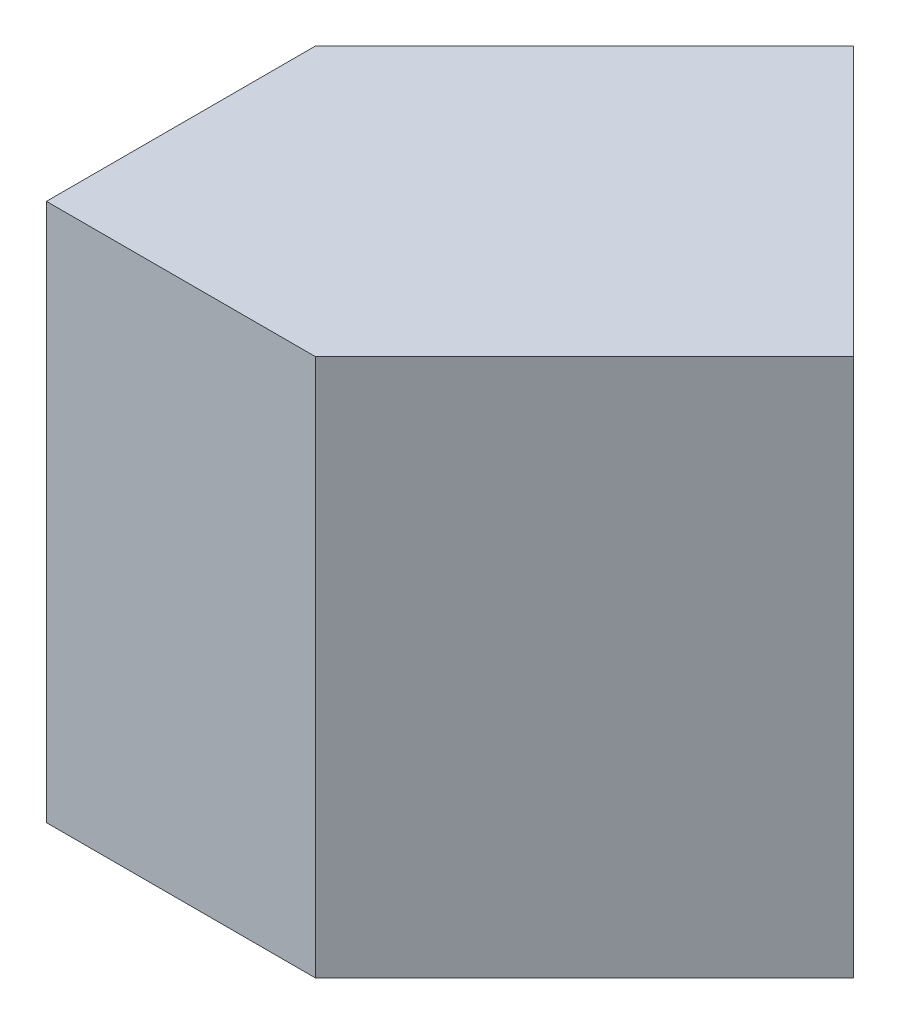
from build123d import *

# Parameters (mm, degrees)
SKETCH1_W           = 20
SKETCH1_H           = 20
BOSS_EXTRUDE1_DEPTH = 20
CUT_EXTRUDE1_DEPTH  = 20
CUT_EXTRUDE2_DEPTH  = 20
CUT_EXTRUDE3_DEPTH  = 20


with BuildPart() as part:
    # Sketch1 → Boss-Extrude1 (new body)
    with BuildSketch(Plane.XY):
        with Locations((10, 10)):
            Rectangle(SKETCH1_W, SKETCH1_H)
    extrude(amount=BOSS_EXTRUDE1_DEPTH)

    # Sketch2 → Cut-Extrude1 (cut)
    with BuildSketch(Plane(origin=(0, 20, 0), x_dir=(1, 0, 0), z_dir=(0, 1, 0))):
        Polygon((20, 0), (10, 0), (20, -10), align=None)
    extrude(amount=-CUT_EXTRUDE1_DEPTH, mode=Mode.SUBTRACT)

    # Sketch3 → Cut-Extrude2 (cut)
    with BuildSketch(Plane(origin=(0, 20, 0), x_dir=(1, 0, 0), z_dir=(0, 1, 0))):
        Polygon((20, -20), (20, -10), (10, -20), align=None)
    extrude(amount=-CUT_EXTRUDE2_DEPTH, mode=Mode.SUBTRACT)

    # Sketch4 → Cut-Extrude3 (cut)
    with BuildSketch(Plane(origin=(0, 20, 0), x_dir=(1, 0, 0), z_dir=(0, 1, 0))):
        Polygon((0, 0), (10, 0), (0, -10), align=None)
    extrude(amount=-CUT_EXTRUDE3_DEPTH, mode=Mode.SUBTRACT)


solid = part.part
